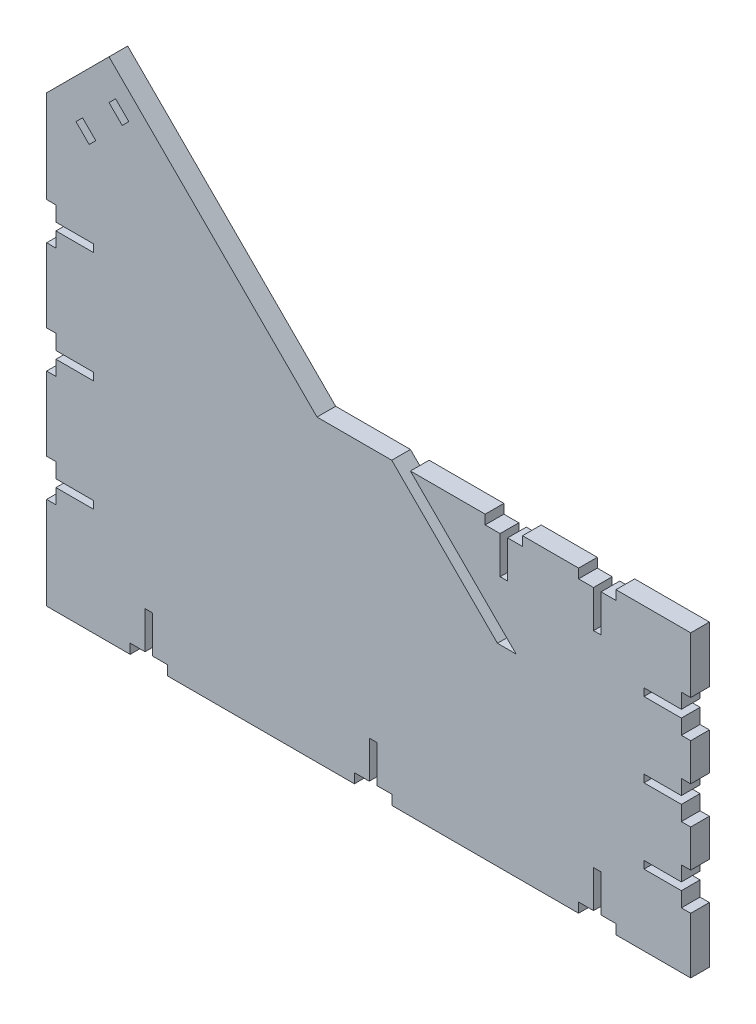
from build123d import *

# Parameters (mm, degrees)
BOSS_EXTRUDE1_DEPTH     = 6.35
CUT_EXTRUDE2_DEPTH      = 2.54
CUT_EXTRUDE2_DEPTH_BACK = 127
CUT_EXTRUDE4_DEPTH      = 127
CUT_EXTRUDE4_DEPTH_BACK = 127
CUT_EXTRUDE5_DEPTH      = 127
CUT_EXTRUDE5_DEPTH_BACK = 127


with BuildPart() as part:
    # Sketch1 → Boss-Extrude1 (new body)
    with BuildSketch(Plane.XY):
        Polygon((0, 0), (127, 0), (127, 101.6), (0, 101.6), (-70.692427737, 172.292427737), (-91.896861793, 151.087993682), (-91.896861793, 0), align=None)
    extrude(amount=BOSS_EXTRUDE1_DEPTH)

    # Sketch2 → Cut-Extrude2 (cut, two sides: drawn at the far end of the back side and taken through both)
    with BuildSketch(Plane(origin=(0, 0, 0), x_dir=(-1, 0, 0), z_dir=(0, 0, -1)).offset(-CUT_EXTRUDE2_DEPTH_BACK)):
        Polygon((-61.321024484, 65.678975516), (-25.4, 101.6), (-31.75, 101.6), (-49.710512242, 83.639487758), (-67.671024484, 65.678975516), align=None)
    extrude(amount=CUT_EXTRUDE2_DEPTH + CUT_EXTRUDE2_DEPTH_BACK, mode=Mode.SUBTRACT)

    # Sketch3 → Cut-Extrude4 (cut, two sides: drawn at the far end of the back side and taken through both)
    with BuildSketch(Plane(origin=(0, 0, 0), x_dir=(-1, 0, 0), z_dir=(0, 0, -1)).offset(-CUT_EXTRUDE4_DEPTH_BACK)):
        Polygon((68.447363707, 161.067107586), (63.957235647, 156.576979525), (66.202299677, 154.331915495), (70.692427737, 158.822043556), align=None)
        Polygon((-127, 31.75), (-127, 19.05), (-123.825, 19.05), (-123.825, 24.1173), (-111.125, 24.1173), (-111.125, 26.6827), (-123.825, 26.6827), (-123.825, 31.75), align=None)
        Polygon((-57.15, 101.6), (-69.85, 101.6), (-69.85, 98.425), (-64.77, 98.425), (-64.77, 85.725), (-62.23, 85.725), (-62.23, 98.425), (-57.15, 98.425), align=None)
        Polygon((-88.9, 101.6), (-101.6, 101.6), (-101.6, 98.425), (-96.5327, 98.425), (-96.5327, 85.725), (-93.9673, 85.725), (-93.9673, 98.425), (-88.9, 98.425), align=None)
        Polygon((-127, 82.55), (-127, 69.85), (-123.825, 69.85), (-123.825, 74.9173), (-111.125, 74.9173), (-111.125, 77.4827), (-123.825, 77.4827), (-123.825, 82.55), align=None)
        Polygon((-127, 57.15), (-127, 44.45), (-123.825, 44.45), (-123.825, 49.5173), (-111.125, 49.5173), (-111.125, 52.0827), (-123.825, 52.0827), (-123.825, 57.15), align=None)
        Polygon((88.721861793, 106.965995261), (91.896861793, 106.965995261), (91.896861793, 119.665995261), (88.721861793, 119.665995261), (88.721861793, 114.598695261), (76.021861793, 114.598695261), (76.021861793, 112.033295261), (88.721861793, 112.033295261), align=None)
        Polygon((88.721861793, 69.193996841), (91.896861793, 69.193996841), (91.896861793, 81.893996841), (88.721861793, 81.893996841), (88.721861793, 76.826696841), (76.021861793, 76.826696841), (76.021861793, 74.261296841), (88.721861793, 74.261296841), align=None)
        Polygon((88.721861793, 31.42199842), (91.896861793, 31.42199842), (91.896861793, 44.12199842), (88.721861793, 44.12199842), (88.721861793, 39.05469842), (76.021861793, 39.05469842), (76.021861793, 36.48929842), (88.721861793, 36.48929842), align=None)
        Polygon((50.8, 3.302), (50.8, 0), (63.5, 0), (63.5, 3.302), (58.4327, 3.302), (58.4327, 16.002), (55.8673, 16.002), (55.8673, 3.302), align=None)
        Polygon((-25.4, 3.302), (-25.4, 0), (-12.7, 0), (-12.7, 3.302), (-17.7673, 3.302), (-17.7673, 16.002), (-20.3327, 16.002), (-20.3327, 3.302), align=None)
        Polygon((-101.6, 3.302), (-101.6, 0), (-88.9, 0), (-88.9, 3.302), (-93.9673, 3.302), (-93.9673, 16.002), (-96.5327, 16.002), (-96.5327, 3.302), align=None)
    extrude(amount=CUT_EXTRUDE4_DEPTH + CUT_EXTRUDE4_DEPTH_BACK, mode=Mode.SUBTRACT)

    # Sketch4 → Cut-Extrude5 (cut, two sides: drawn at the far end of the back side and taken through both)
    with BuildSketch(Plane.XY.offset(-CUT_EXTRUDE5_DEPTH_BACK)):
        Polygon((-81.917747889, 147.596723404), (-79.672683858, 149.841787435), (-75.182555798, 145.351659374), (-77.427619828, 143.106595344), align=None)
    extrude(amount=CUT_EXTRUDE5_DEPTH + CUT_EXTRUDE5_DEPTH_BACK, mode=Mode.SUBTRACT)


solid = part.part
